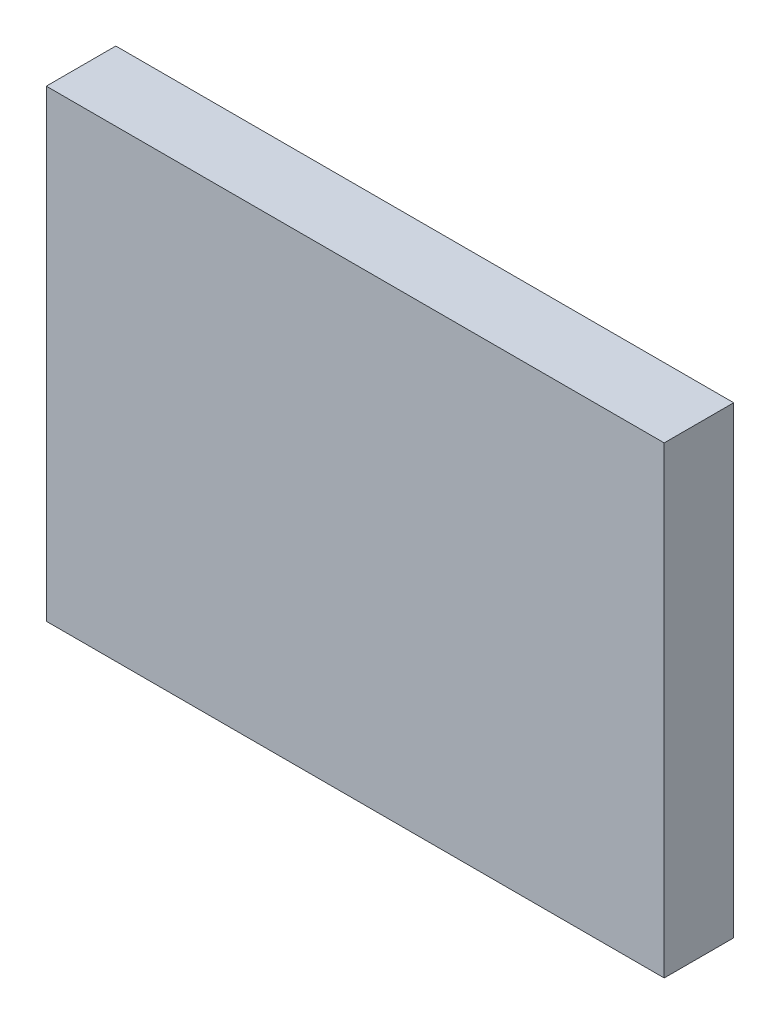
from build123d import *

# Parameters (mm, degrees)
SKETCH1_W           = 160
SKETCH1_H           = 120
BOSS_EXTRUDE1_DEPTH = 18


with BuildPart() as part:
    # Sketch1 → Boss-Extrude1 (new body)
    with BuildSketch(Plane.XY):
        Rectangle(SKETCH1_W, SKETCH1_H)
    extrude(amount=BOSS_EXTRUDE1_DEPTH)


solid = part.part
